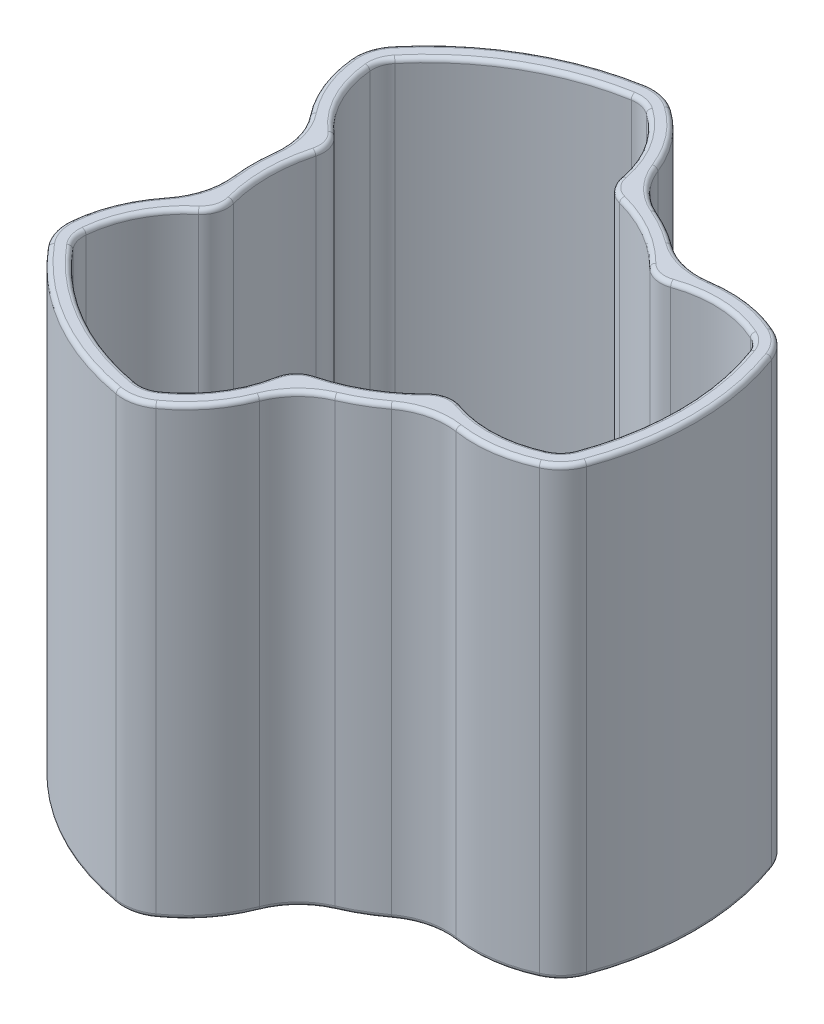
from build123d import *

# Parameters (mm, degrees)
DODANIE_WYCI_GNI_CIE1_DEPTH = 44.5
DODANIE_WYCI_GNI_CIE2_START = -7
DODANIE_WYCI_GNI_CIE2_DEPTH = 7
SZKIC2_R                    = 6.5
WYTNIJ_WYCI_GNI_CIE1_DEPTH  = 17
ZAOKR_GLENIE1_R             = 3
SFAZOWANIE2_SIZE            = 0.5
ZAOKR_GLENIE8_R             = 5
ZAOKR_GLENIE9_R             = 8
ZAOKR_GLENIE5_R             = 0.5
WYTNIJ_WYCI_GNI_CIE3_DEPTH  = 15


with BuildPart() as part:
    # Szkic1 → Dodanie-wyci_gni_cie1 (new body)
    with BuildSketch(Plane(origin=(0, 0, 0), x_dir=(1, 0, 0), z_dir=(0, 1, 0))):
        with BuildLine():
            ThreePointArc((28.388362069, -12.453951142), (31, 0), (28.388362069, 12.453951142))
            ThreePointArc((28.388362069, 12.453951142), (21.740524876, 14.779965767), (14.768657635, 13.781391499))
            ThreePointArc((14.768657635, 13.781391499), (10.1, 17.493713156), (4.55070632, 19.680728442))
            ThreePointArc((4.55070632, 19.680728442), (1.929563384, 26.217829718), (-3.408742968, 30.812018294))
            ThreePointArc((-3.408742968, 30.812018294), (-15.5, 26.846787517), (-24.979619101, 18.358067153))
            ThreePointArc((-24.979619101, 18.358067153), (-23.670088259, 11.43786395), (-19.319363955, 5.899336943))
            ThreePointArc((-19.319363955, 5.899336943), (-20.2, 0), (-19.319363955, -5.899336943))
            ThreePointArc((-19.319363955, -5.899336943), (-23.670088259, -11.43786395), (-24.979619101, -18.358067153))
            ThreePointArc((-24.979619101, -18.358067153), (-15.5, -26.846787517), (-3.408742968, -30.812018294))
            ThreePointArc((-3.408742968, -30.812018294), (1.929563384, -26.217829718), (4.55070632, -19.680728442))
            ThreePointArc((4.55070632, -19.680728442), (10.1, -17.493713156), (14.768657635, -13.781391499))
            ThreePointArc((14.768657635, -13.781391499), (21.740524876, -14.779965767), (28.388362069, -12.453951142))
        make_face()
        with BuildLine():
            ThreePointArc((26.797229064, -11.086411254), (29, 0), (26.797229064, 11.086411254))
            ThreePointArc((26.797229064, 11.086411254), (20.551461681, 12.847539337), (14.241564039, 11.332160152))
            ThreePointArc((14.241564039, 11.332160152), (9.1, 15.761662349), (2.693156552, 17.999636324))
            ThreePointArc((2.693156552, 17.999636324), (0.850564602, 24.22185757), (-3.797500749, 28.750286747))
            ThreePointArc((-3.797500749, 28.750286747), (-14.5, 25.11473671), (-22.999728315, 17.663875494))
            ThreePointArc((-22.999728315, 17.663875494), (-21.402026283, 11.374318232), (-16.934720591, 6.667476172))
            ThreePointArc((-16.934720591, 6.667476172), (-18.2, 0), (-16.934720591, -6.667476172))
            ThreePointArc((-16.934720591, -6.667476172), (-21.402026283, -11.374318232), (-22.999728315, -17.663875494))
            ThreePointArc((-22.999728315, -17.663875494), (-14.5, -25.11473671), (-3.797500749, -28.750286747))
            ThreePointArc((-3.797500749, -28.750286747), (0.850564602, -24.22185757), (2.693156552, -17.999636324))
            ThreePointArc((2.693156552, -17.999636324), (9.1, -15.761662349), (14.241564039, -11.332160152))
            ThreePointArc((14.241564039, -11.332160152), (20.551461681, -12.847539337), (26.797229064, -11.086411254))
        make_face(mode=Mode.SUBTRACT)
    extrude(amount=DODANIE_WYCI_GNI_CIE1_DEPTH)

    # Szkic1_2 → Dodanie-wyci_gni_cie2 (add)
    with BuildSketch(Plane(origin=(0, 0, 0), x_dir=(1, 0, 0), z_dir=(0, 1, 0)).offset(DODANIE_WYCI_GNI_CIE2_START)):
        with BuildLine():
            ThreePointArc((28.388362069, -12.453951142), (31, 0), (28.388362069, 12.453951142))
            ThreePointArc((28.388362069, 12.453951142), (21.740524876, 14.779965767), (14.768657635, 13.781391499))
            ThreePointArc((14.768657635, 13.781391499), (10.1, 17.493713156), (4.55070632, 19.680728442))
            ThreePointArc((4.55070632, 19.680728442), (1.929563384, 26.217829718), (-3.408742968, 30.812018294))
            ThreePointArc((-3.408742968, 30.812018294), (-15.5, 26.846787517), (-24.979619101, 18.358067153))
            ThreePointArc((-24.979619101, 18.358067153), (-23.670088259, 11.43786395), (-19.319363955, 5.899336943))
            ThreePointArc((-19.319363955, 5.899336943), (-20.2, 0), (-19.319363955, -5.899336943))
            ThreePointArc((-19.319363955, -5.899336943), (-23.670088259, -11.43786395), (-24.979619101, -18.358067153))
            ThreePointArc((-24.979619101, -18.358067153), (-15.5, -26.846787517), (-3.408742968, -30.812018294))
            ThreePointArc((-3.408742968, -30.812018294), (1.929563384, -26.217829718), (4.55070632, -19.680728442))
            ThreePointArc((4.55070632, -19.680728442), (10.1, -17.493713156), (14.768657635, -13.781391499))
            ThreePointArc((14.768657635, -13.781391499), (21.740524876, -14.779965767), (28.388362069, -12.453951142))
        make_face()
    extrude(amount=DODANIE_WYCI_GNI_CIE2_DEPTH)

    # Szkic2 → Wytnij-wyci_gni_cie1 (cut)
    with BuildSketch(Plane(origin=(0, -7, 0), x_dir=(-1, 0, 0), z_dir=(0, -1, 0))):
        with Locations((-15, 0)):
            Circle(SZKIC2_R)
        with Locations((7.5, -12.990381057)):
            Circle(SZKIC2_R)
        with Locations((7.5, 12.990381057)):
            Circle(SZKIC2_R)
    extrude(amount=-WYTNIJ_WYCI_GNI_CIE1_DEPTH, mode=Mode.SUBTRACT)

    # Zaokr_glenie1
    zaokr_glenie1_edges = [part.edges().sort_by_distance(p)[0] for p in [
        (14.241564039, 22.25, -11.332160152),
        (2.693156552, 22.25, -17.999636324),
        (-3.797500749, 22.25, -28.750286747),
        (-22.999728315, 22.25, -17.663875494),
        (-16.934720591, 22.25, -6.667476172),
        (-16.934720591, 22.25, 6.667476172),
        (-22.999728315, 22.25, 17.663875494),
        (-3.797500749, 22.25, 28.750286747),
        (2.693156552, 22.25, 17.999636324),
        (14.241564039, 22.25, 11.332160152),
        (26.797229064, 22.25, 11.086411254),
        (26.797229064, 22.25, -11.086411254),
    ]]
    fillet(zaokr_glenie1_edges, radius=ZAOKR_GLENIE1_R)

    # Sfazowanie2
    sfazowanie2_edges = [part.edges().sort_by_distance(p)[0] for p in [
        (21.5, 0, 0),
        (-1, 0, 12.990381057),
        (-1, 0, -12.990381057),
    ]]
    chamfer(sfazowanie2_edges, length=SFAZOWANIE2_SIZE)

    # Zaokr_glenie8
    zaokr_glenie8_edges = [part.edges().sort_by_distance(p)[0] for p in [
        (-24.979619101, 18.75, -18.358067153),
        (-24.979619101, 18.75, 18.358067153),
        (-3.408742968, 18.75, 30.812018294),
        (-3.408742968, 18.75, -30.812018294),
        (28.388362069, 18.75, -12.453951142),
        (28.388362069, 18.75, 12.453951142),
    ]]
    fillet(zaokr_glenie8_edges, radius=ZAOKR_GLENIE8_R)

    # Zaokr_glenie9
    zaokr_glenie9_edges = [part.edges().sort_by_distance(p)[0] for p in [
        (14.768657635, 18.75, 13.781391499),
        (4.55070632, 18.75, 19.680728442),
        (14.768657635, 18.75, -13.781391499),
        (4.55070632, 18.75, -19.680728442),
        (-19.319363955, 18.75, -5.899336943),
        (-19.319363955, 18.75, 5.899336943),
    ]]
    fillet(zaokr_glenie9_edges, radius=ZAOKR_GLENIE9_R)

    # Zaokr_glenie5
    zaokr_glenie5_edges = [part.edges().sort_by_distance(p)[0] for p in [
        (14.3637981, 44.5, -12.024416577),
        (20.888894298, 44.5, -12.83649888),
        (26.613978722, 44.5, -10.987196446),
        (29, 44.5, 0),
        (26.613978722, 44.5, 10.987196446),
        (20.888894298, 44.5, 12.83649888),
        (14.3637981, 44.5, 12.024416577),
        (9.1, 44.5, 15.761662349),
        (3.231551171, 44.5, 18.451622338),
        (0.672286977, 44.5, 24.50856256),
        (-3.791798122, 44.5, 28.541979892),
        (-14.5, 44.5, 25.11473671),
        (-22.8221806, 44.5, 17.554783446),
        (-21.561181275, 44.5, 11.672063679),
        (-17.595349271, 44.5, 6.427205761),
        (-18.2, 44.5, 0),
        (-17.595349271, 44.5, -6.427205761),
        (-21.561181275, 44.5, -11.672063679),
        (-22.8221806, 44.5, -17.554783446),
        (-14.5, 44.5, -25.11473671),
        (-3.791798122, 44.5, -28.541979892),
        (0.672286977, 44.5, -24.50856256),
        (3.231551171, 44.5, -18.451622338),
        (9.1, 44.5, -15.761662349),
        (10.1, 44.5, 17.493713156),
        (1.548000776, 44.5, 26.727953525),
        (-15.5, 44.5, 26.846787517),
        (-23.921087132, 44.5, 12.023368765),
        (-20.2, 44.5, 0),
        (-23.921087132, 44.5, -12.023368765),
        (-15.5, 44.5, -26.846787517),
        (1.548000776, 44.5, -26.727953525),
        (10.1, 44.5, -17.493713156),
        (22.373086356, 44.5, -14.70458476),
        (31, 44.5, 0),
        (22.373086356, 44.5, 14.70458476),
        (-3.350864687, 44.5, -30.492768888),
        (5.379208726, 44.5, -20.347454321),
        (14.931807981, 44.5, -14.832258569),
        (28.082944832, 44.5, -12.3444505),
        (28.082944832, 44.5, 12.3444505),
        (14.931807981, 44.5, 14.832258569),
        (5.379208726, 44.5, 20.347454321),
        (-3.350864687, 44.5, 30.492768888),
        (-24.732080145, 44.5, 18.148318388),
        (-20.311016707, 44.5, 5.515195751),
        (-20.311016707, 44.5, -5.515195751),
        (-24.732080145, 44.5, -18.148318388),
        (-20.311016707, -7, -5.515195751),
        (-20.2, -7, 0),
        (-20.311016707, -7, 5.515195751),
        (-23.921087132, -7, 12.023368765),
        (-24.732080145, -7, 18.148318388),
        (-15.5, -7, 26.846787517),
        (-3.350864687, -7, 30.492768888),
        (1.548000776, -7, 26.727953525),
        (5.379208726, -7, 20.347454321),
        (10.1, -7, 17.493713156),
        (14.931807981, -7, 14.832258569),
        (22.373086356, -7, 14.70458476),
        (28.082944832, -7, 12.3444505),
        (31, -7, 0),
        (28.082944832, -7, -12.3444505),
        (22.373086356, -7, -14.70458476),
        (14.931807981, -7, -14.832258569),
        (10.1, -7, -17.493713156),
        (5.379208726, -7, -20.347454321),
        (1.548000776, -7, -26.727953525),
        (-3.350864687, -7, -30.492768888),
        (-15.5, -7, -26.846787517),
        (-24.732080145, -7, -18.148318388),
        (-23.921087132, -7, -12.023368765),
        (21.5, -7, 0),
        (-1, -7, -12.990381057),
        (-1, -7, 12.990381057),
    ]]
    fillet(zaokr_glenie5_edges, radius=ZAOKR_GLENIE5_R)

    # Szkic5 → Wytnij-wyci_gni_cie3 (cut)
    with BuildSketch(Plane.XZ.offset(7)):
        with BuildLine():
            ThreePointArc((-2.71813176, -28.063150927), (0.672286977, -24.50856256), (2.481199908, -19.941520664))
            ThreePointArc((2.481199908, -19.941520664), (3.231551171, -18.451622338), (4.661705225, -17.592853788))
            ThreePointArc((4.661705225, -17.592853788), (9.1, -15.761662349), (12.905005693, -12.833582043))
            ThreePointArc((12.905005693, -12.833582043), (14.3637981, -12.024416577), (16.029263531, -12.119542484))
            ThreePointArc((16.029263531, -12.119542484), (20.888894298, -12.83649888), (25.662467493, -11.677604309))
            ThreePointArc((25.662467493, -11.677604309), (26.613978722, -10.987196446), (27.227129121, -9.984159446))
            ThreePointArc((27.227129121, -9.984159446), (29, 0), (27.227129121, 9.984159446))
            ThreePointArc((27.227129121, 9.984159446), (26.613978722, 10.987196446), (25.662467493, 11.677604309))
            ThreePointArc((25.662467493, 11.677604309), (20.888894298, 12.83649888), (16.029263531, 12.119542484))
            ThreePointArc((16.029263531, 12.119542484), (14.3637981, 12.024416577), (12.905005693, 12.833582043))
            ThreePointArc((12.905005693, 12.833582043), (9.1, 15.761662349), (4.661705225, 17.592853788))
            ThreePointArc((4.661705225, 17.592853788), (3.231551171, 18.451622338), (2.481199908, 19.941520664))
            ThreePointArc((2.481199908, 19.941520664), (0.672286977, 24.50856256), (-2.71813176, 28.063150927))
            ThreePointArc((-2.71813176, 28.063150927), (-3.791798122, 28.541979892), (-4.967028845, 28.571465214))
            ThreePointArc((-4.967028845, 28.571465214), (-14.5, 25.11473671), (-22.260100276, 18.587305768))
            ThreePointArc((-22.260100276, 18.587305768), (-22.8221806, 17.554783446), (-22.944335733, 16.385546618))
            ThreePointArc((-22.944335733, 16.385546618), (-21.561181275, 11.672063679), (-18.510463439, 7.82197818))
            ThreePointArc((-18.510463439, 7.82197818), (-17.595349271, 6.427205761), (-17.566710918, 4.759271744))
            ThreePointArc((-17.566710918, 4.759271744), (-18.2, 0), (-17.566710918, -4.759271744))
            ThreePointArc((-17.566710918, -4.759271744), (-17.595349271, -6.427205761), (-18.510463439, -7.82197818))
            ThreePointArc((-18.510463439, -7.82197818), (-21.561181275, -11.672063679), (-22.944335733, -16.385546618))
            ThreePointArc((-22.944335733, -16.385546618), (-22.8221806, -17.554783446), (-22.260100276, -18.587305768))
            ThreePointArc((-22.260100276, -18.587305768), (-14.5, -25.11473671), (-4.967028845, -28.571465214))
            ThreePointArc((-4.967028845, -28.571465214), (-3.791798122, -28.541979892), (-2.71813176, -28.063150927))
        make_face()
    extrude(amount=-WYTNIJ_WYCI_GNI_CIE3_DEPTH, mode=Mode.SUBTRACT)


solid = part.part
